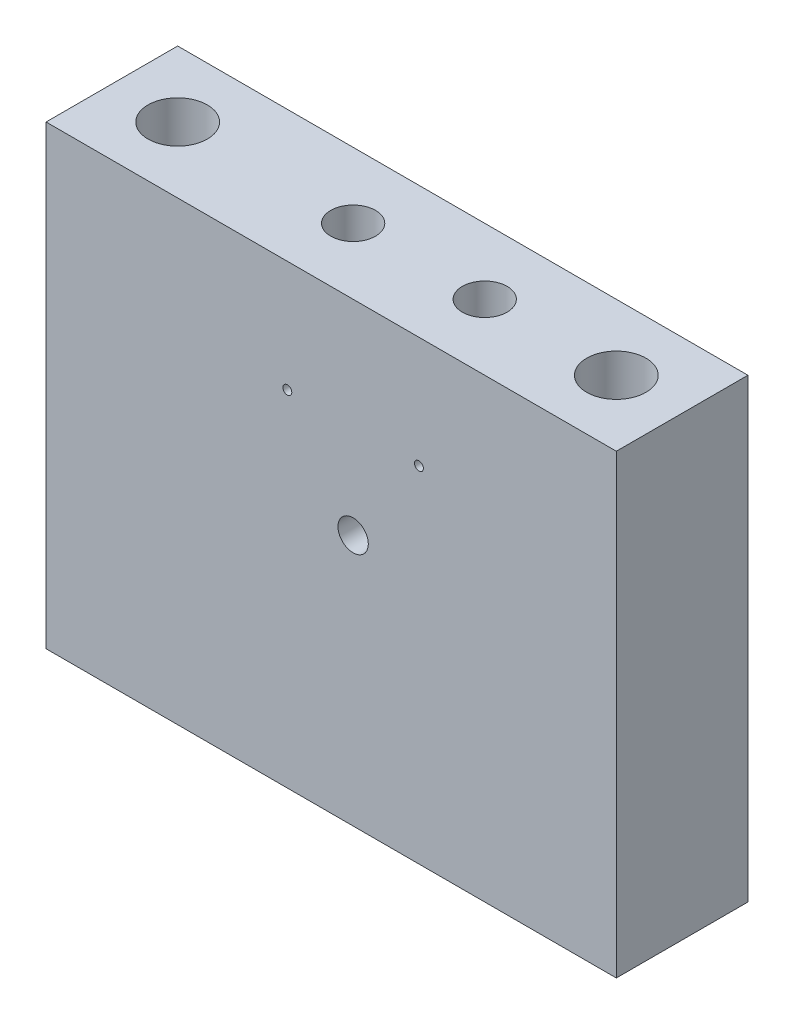
from build123d import *

# Parameters (mm, degrees)
SKETCH1_W                   = 65
SKETCH1_H                   = 52
BASE_EXTRUDE_DEPTH          = 7.5
F_1_4_20_TAPPED_HOLE1_D     = 5.1054
F_1_4_20_TAPPED_HOLE1_DEPTH = 16.51
F_1_4_20_TAPPED_HOLE1_TIP   = 1.533816902
F_1_4_CLEARANCE_HOLE1_D     = 6.7564
F_8_32_TAPPED_HOLE1_D       = 3.4544
CUT_EXTRUDE1_REACH          = 17
SKETCH8_R                   = 0.508


with BuildPart() as part:
    # Sketch1 → Base-Extrude (new body, symmetric)
    with BuildSketch(Plane.XY):
        Rectangle(SKETCH1_W, SKETCH1_H)
    extrude(amount=BASE_EXTRUDE_DEPTH, both=True)

    # 1/4-20 Tapped Hole1
    with Locations(Plane(origin=(0, 26, 0), x_dir=(-1, 0, 0), z_dir=(0, 1, 0))):
        with Locations((5, 0), (-10, 0)):
            Hole(F_1_4_20_TAPPED_HOLE1_D / 2, depth=F_1_4_20_TAPPED_HOLE1_DEPTH)
            with Locations((0, 0, -(F_1_4_20_TAPPED_HOLE1_DEPTH + F_1_4_20_TAPPED_HOLE1_TIP / 2))):  # 118° drill point
                Cone(0, F_1_4_20_TAPPED_HOLE1_D / 2, F_1_4_20_TAPPED_HOLE1_TIP, mode=Mode.SUBTRACT)

    # 1/4 Clearance Hole1 (through all)
    with Locations(Plane(origin=(0, 26, 0), x_dir=(-1, 0, 0), z_dir=(0, 1, 0))):
        with Locations((-25, 0), (25, 0)):
            Hole(F_1_4_CLEARANCE_HOLE1_D / 2)

    # #8-32 Tapped Hole1 (through all)
    with Locations(Plane(origin=(0, 0, -7.5), x_dir=(-1, 0, 0), z_dir=(0, 0, -1))):
        with Locations((-2.5, 2.7)):
            Hole(F_8_32_TAPPED_HOLE1_D / 2)

    # Sketch8 → Cut-Extrude1 (cut, up to next)
    with BuildSketch(Plane.XY.offset(7.5), mode=Mode.PRIVATE) as cut_extrude1_sk1:
        with Locations((10, 13.3)):
            Circle(SKETCH8_R)
    cut_extrude1_tool1 = extrude(cut_extrude1_sk1.sketch, amount=-CUT_EXTRUDE1_REACH, mode=Mode.PRIVATE) & part.part
    add(cut_extrude1_tool1.solids().sort_by_distance((10, 13.3, 7.5))[0], mode=Mode.SUBTRACT)
    # Sketch8 → Cut-Extrude1 (cut, up to next)
    with BuildSketch(Plane.XY.offset(7.5), mode=Mode.PRIVATE) as cut_extrude1_sk2:
        with Locations((-5, 13.3)):
            Circle(SKETCH8_R)
    cut_extrude1_tool2 = extrude(cut_extrude1_sk2.sketch, amount=-CUT_EXTRUDE1_REACH, mode=Mode.PRIVATE) & part.part
    add(cut_extrude1_tool2.solids().sort_by_distance((-5, 13.3, 7.5))[0], mode=Mode.SUBTRACT)


solid = part.part
